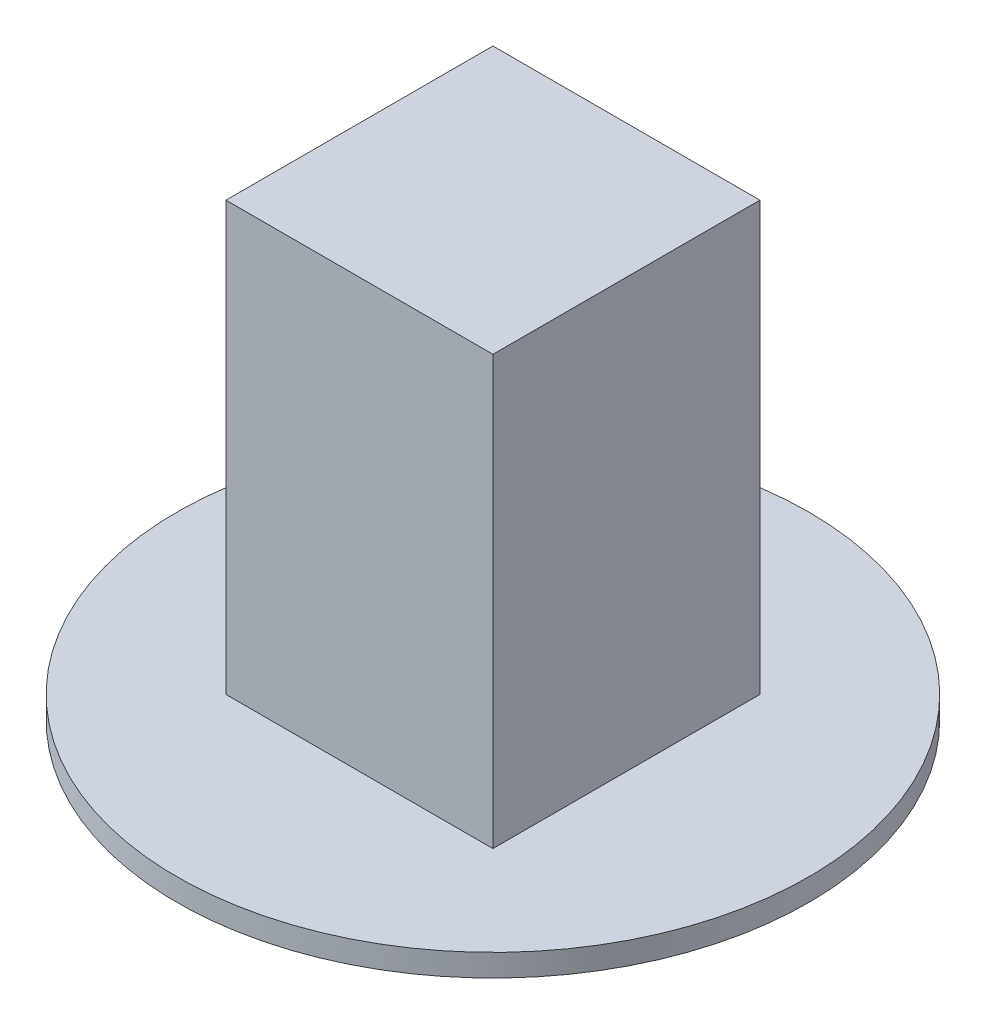
from build123d import *

# Parameters (mm, degrees)
SKETCH1_W           = 38.1
SKETCH1_H           = 38.1
BOSS_EXTRUDE1_DEPTH = 61.087
SKETCH2_R           = 45.085
BOSS_EXTRUDE2_DEPTH = 3.175


with BuildPart() as part:
    # Sketch1 → Boss-Extrude1 (new body)
    with BuildSketch(Plane(origin=(0, 0, 0), x_dir=(1, 0, 0), z_dir=(0, 1, 0))):
        Rectangle(SKETCH1_W, SKETCH1_H)
    extrude(amount=BOSS_EXTRUDE1_DEPTH)

    # Sketch2 → Boss-Extrude2 (add)
    with BuildSketch(Plane.XZ):
        Circle(SKETCH2_R)
    extrude(amount=BOSS_EXTRUDE2_DEPTH)


solid = part.part
